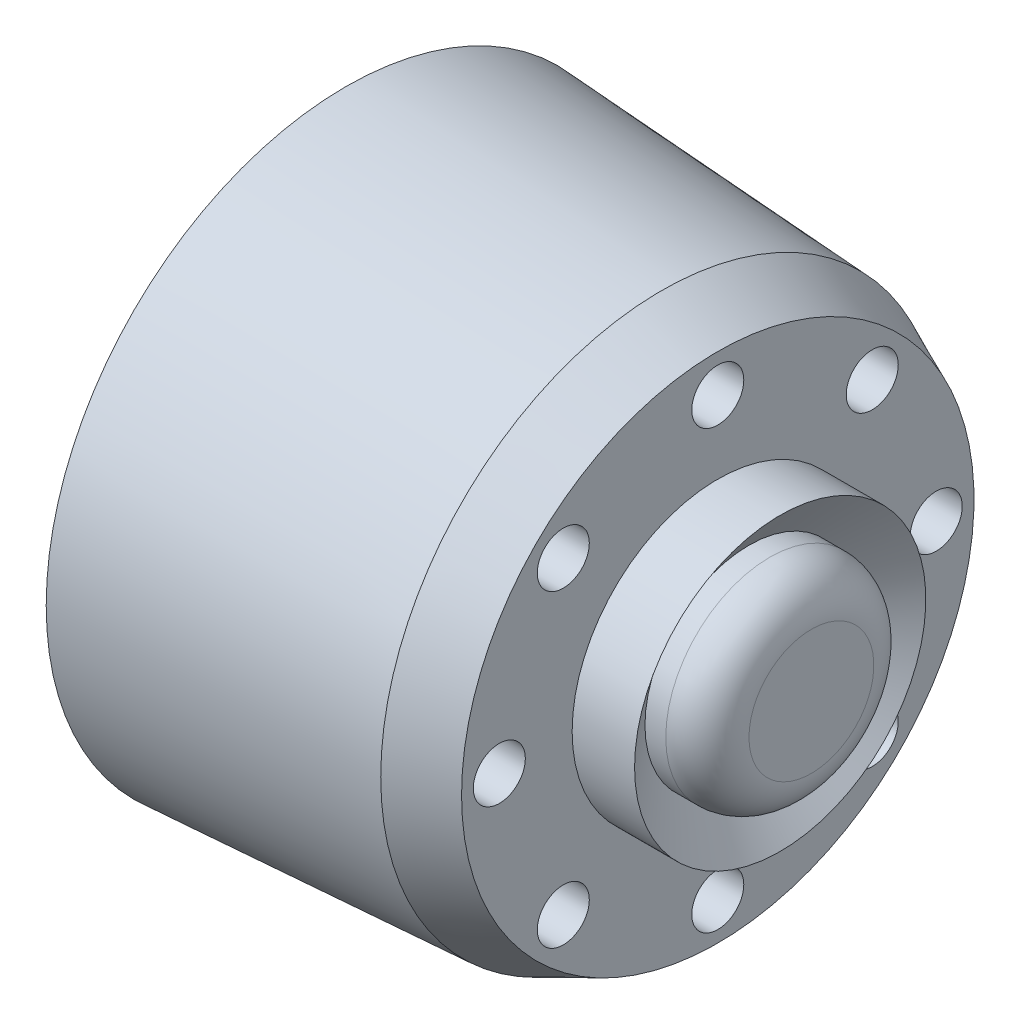
from build123d import *

# Parameters (mm, degrees)
SKETCH2_R          = 4.725
CUT_EXTRUDE1_DEPTH = 7
SKETCH3_R          = 1.25
CUT_EXTRUDE2_DEPTH = 18.878835952
SKETCH4_R          = 2.5
CUT_EXTRUDE3_DEPTH = 14.878836
FILLET1_R          = 2


with BuildPart() as part:
    # Sketch1 → Revolve1 (revolve)
    with BuildSketch(Plane(origin=(0, 0, 0), x_dir=(1, 0, 0), z_dir=(0, 1, 0))):
        Polygon((11.693859716, 12.315), (11.693859716, 7), (14.693859716, 7), (13.193859716, 5), (14.693859716, 5), (16.193859716, 5), (16.193859716, 0), (-6.184976236, 0), (-6.184976236, 14.4), (8.993859716, 13.5), align=None)
    revolve(axis=Axis((-18.233766234, 0, 0), (1, 0, 0)))

    # Sketch2 → Cut-Extrude1 (cut)
    with BuildSketch(Plane.ZY.offset(6.184976236)):
        Circle(SKETCH2_R)
    extrude(amount=-CUT_EXTRUDE1_DEPTH, mode=Mode.SUBTRACT)

    # Sketch3 → Cut-Extrude2 (cut, through all)
    with BuildSketch(Plane(origin=(11.693859716, 0, 0), x_dir=(0, 0, -1), z_dir=(1, 0, 0))):
        with Locations((0, 10.5)):
            Circle(SKETCH3_R)
        with Locations((7.424621202, 7.424621202)):
            Circle(SKETCH3_R)
        with Locations((10.5, 0)):
            Circle(SKETCH3_R)
        with Locations((7.424621202, -7.424621202)):
            Circle(SKETCH3_R)
        with Locations((0, -10.5)):
            Circle(SKETCH3_R)
        with Locations((-7.424621202, -7.424621202)):
            Circle(SKETCH3_R)
        with Locations((-10.5, 0)):
            Circle(SKETCH3_R)
        with Locations((-7.424621202, 7.424621202)):
            Circle(SKETCH3_R)
    extrude(amount=-CUT_EXTRUDE2_DEPTH, mode=Mode.SUBTRACT)

    # Sketch4 → Cut-Extrude3 (cut)
    with BuildSketch(Plane.ZY.offset(6.184976236)):
        with Locations((0, 10.5)):
            Circle(SKETCH4_R)
        with Locations((7.424621202, 7.424621202)):
            Circle(SKETCH4_R)
        with Locations((10.5, 0)):
            Circle(SKETCH4_R)
        with Locations((7.424621202, -7.424621202)):
            Circle(SKETCH4_R)
        with Locations((0, -10.5)):
            Circle(SKETCH4_R)
        with Locations((-7.424621202, -7.424621202)):
            Circle(SKETCH4_R)
        with Locations((-10.5, 0)):
            Circle(SKETCH4_R)
        with Locations((-7.424621202, 7.424621202)):
            Circle(SKETCH4_R)
    extrude(amount=-CUT_EXTRUDE3_DEPTH, mode=Mode.SUBTRACT)

    # Fillet1
    fillet1_edges = [part.edges().sort_by_distance(p)[0] for p in [
        (16.193859716, 0, 5),
    ]]
    fillet(fillet1_edges, radius=FILLET1_R)


solid = part.part
